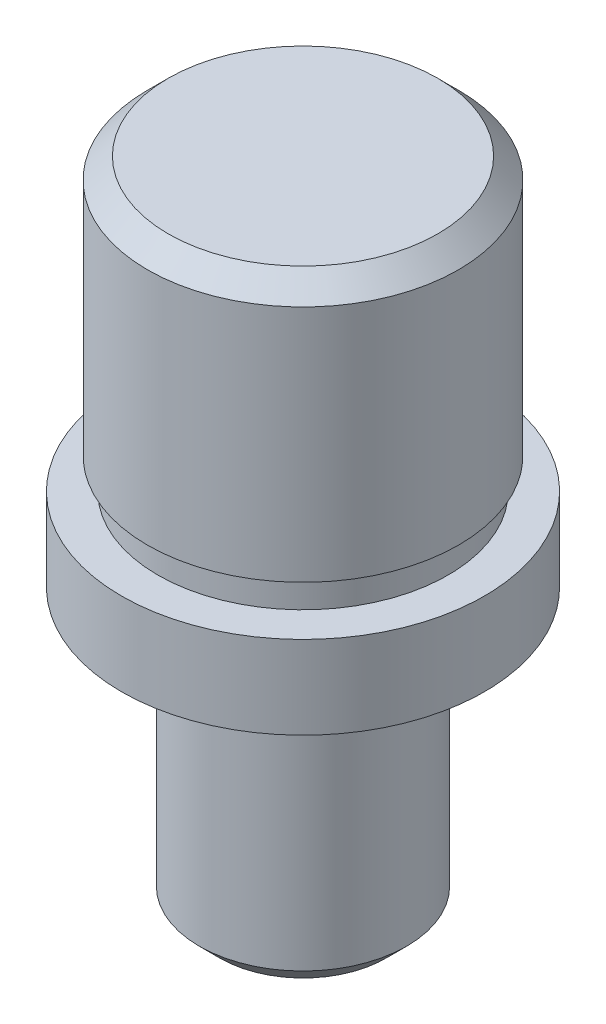
from build123d import *

# Parameters (mm, degrees)
SKETCH_1_R          = 17.5
EXTRUDE_1_DEPTH     = 63
SKETCH_2_OUTSIDE_W  = 53.024
SKETCH_2_OUTSIDE_H  = 53.024
SKETCH_2_OUTSIDE_R  = 15
CUT_EXTRUDE_1_DEPTH = 25
SKETCH_3_OUTSIDE_W  = 53.024
SKETCH_3_OUTSIDE_H  = 53.024
SKETCH_3_OUTSIDE_R  = 14
CUT_EXTRUDE_2_DEPTH = 3
SKETCH_4_OUTSIDE_W  = 53.024
SKETCH_4_OUTSIDE_H  = 53.024
SKETCH_4_OUTSIDE_R  = 10
CUT_EXTRUDE_3_DEPTH = 25
SKETCH_5_OUTSIDE_W  = 53.024
SKETCH_5_OUTSIDE_H  = 53.024
SKETCH_5_OUTSIDE_R  = 9
CUT_EXTRUDE_4_DEPTH = 2
CHAMFER_1_SIZE      = 2


with BuildPart() as part:
    # 草图1 → 凸台-拉伸1 (new body)
    with BuildSketch(Plane(origin=(0, 0, 0), x_dir=(1, 0, 0), z_dir=(0, 1, 0))):
        Circle(SKETCH_1_R)
    extrude(amount=EXTRUDE_1_DEPTH)

    # 草图2 outside → 切除-拉伸1 (cut)
    with BuildSketch(Plane(origin=(0, 63, 0), x_dir=(1, 0, 0), z_dir=(0, 1, 0))):
        Rectangle(SKETCH_2_OUTSIDE_W, SKETCH_2_OUTSIDE_H)
        Circle(SKETCH_2_OUTSIDE_R, mode=Mode.SUBTRACT)
    extrude(amount=-CUT_EXTRUDE_1_DEPTH, mode=Mode.SUBTRACT)

    # 草图3 outside → 切除-拉伸2 (cut)
    with BuildSketch(Plane(origin=(0, 38, 0), x_dir=(1, 0, 0), z_dir=(0, 1, 0))):
        Rectangle(SKETCH_3_OUTSIDE_W, SKETCH_3_OUTSIDE_H)
        Circle(SKETCH_3_OUTSIDE_R, mode=Mode.SUBTRACT)
    extrude(amount=-CUT_EXTRUDE_2_DEPTH, mode=Mode.SUBTRACT)

    # 草图4 outside → 切除-拉伸3 (cut)
    with BuildSketch(Plane.XZ):
        Rectangle(SKETCH_4_OUTSIDE_W, SKETCH_4_OUTSIDE_H)
        Circle(SKETCH_4_OUTSIDE_R, mode=Mode.SUBTRACT)
    extrude(amount=-CUT_EXTRUDE_3_DEPTH, mode=Mode.SUBTRACT)

    # 草图5 outside → 切除-拉伸4 (cut)
    with BuildSketch(Plane.XZ.offset(-25)):
        Rectangle(SKETCH_5_OUTSIDE_W, SKETCH_5_OUTSIDE_H)
        Circle(SKETCH_5_OUTSIDE_R, mode=Mode.SUBTRACT)
    extrude(amount=-CUT_EXTRUDE_4_DEPTH, mode=Mode.SUBTRACT)

    # 倒角1
    chamfer_1_edges = [part.edges().sort_by_distance(p)[0] for p in [
        (-15, 63, 0),
        (-10, 0, 0),
    ]]
    chamfer(chamfer_1_edges, length=CHAMFER_1_SIZE)


solid = part.part
